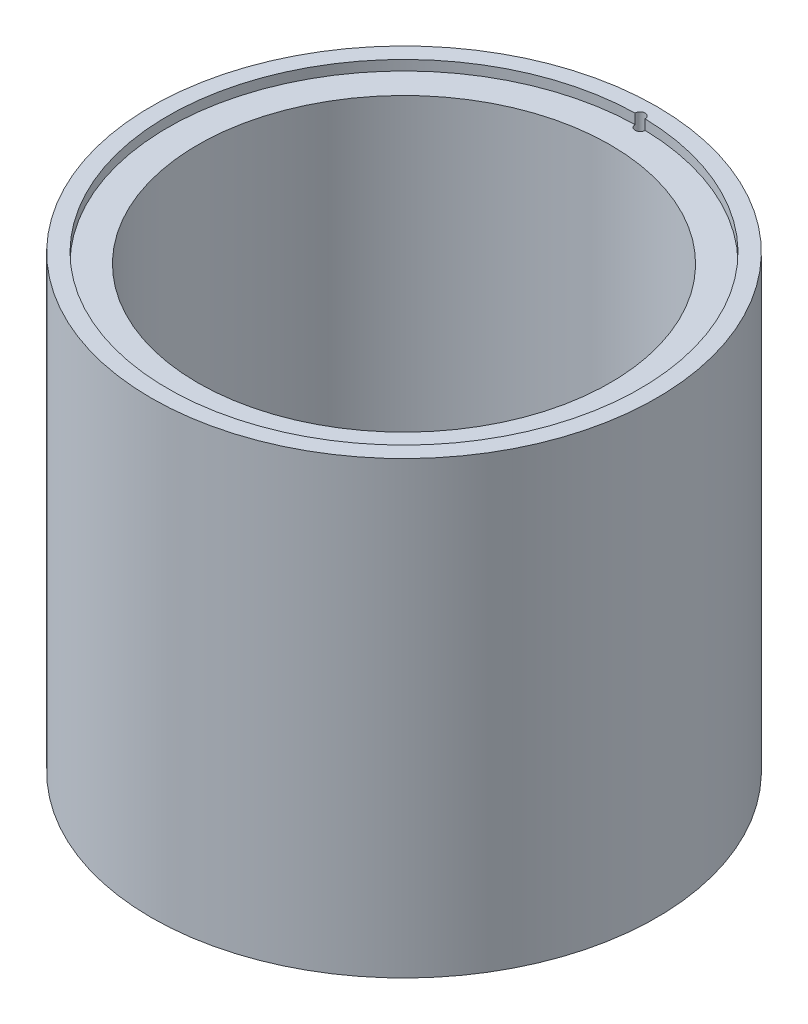
from build123d import *

# Parameters (mm, degrees)
SKETCH1_R           = 25.275
SKETCH1_R_2         = 20.625
BOSS_EXTRUDE1_DEPTH = 45
SKETCH2_R           = 22.625
CUT_EXTRUDE1_DEPTH  = 3.5
SKETCH3_R           = 23.625
CUT_EXTRUDE2_DEPTH  = 1
SKETCH4_R           = 0.5
CUT_EXTRUDE3_DEPTH  = 47.5


with BuildPart() as part:
    # Sketch1 → Boss-Extrude1 (new body)
    with BuildSketch(Plane(origin=(0, 0, 0), x_dir=(1, 0, 0), z_dir=(0, 1, 0))):
        Circle(SKETCH1_R)
        Circle(SKETCH1_R_2, mode=Mode.SUBTRACT)
    extrude(amount=BOSS_EXTRUDE1_DEPTH)

    # Sketch2 → Cut-Extrude1 (cut)
    with BuildSketch(Plane.XZ):
        Circle(SKETCH2_R)
    extrude(amount=-CUT_EXTRUDE1_DEPTH, mode=Mode.SUBTRACT)

    # Sketch3 → Cut-Extrude2 (cut)
    with BuildSketch(Plane(origin=(0, 45, 0), x_dir=(1, 0, 0), z_dir=(0, 1, 0))):
        Circle(SKETCH3_R)
    extrude(amount=-CUT_EXTRUDE2_DEPTH, mode=Mode.SUBTRACT)

    # Sketch4 → Cut-Extrude3 (cut)
    with BuildSketch(Plane(origin=(0, 45, 0), x_dir=(1, 0, 0), z_dir=(0, 1, 0))):
        with Locations((0, 23.625)):
            Circle(SKETCH4_R)
    extrude(amount=-CUT_EXTRUDE3_DEPTH, mode=Mode.SUBTRACT)


solid = part.part
